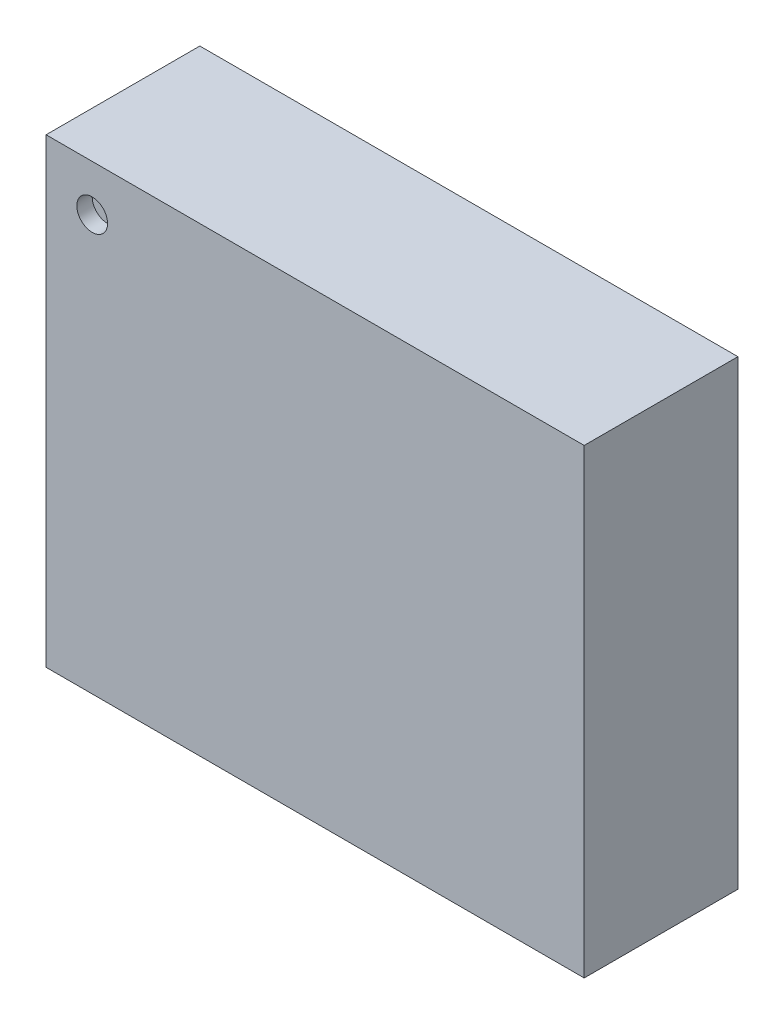
from build123d import *

# Parameters (mm, degrees)
SKETCH1_W           = 3.5
SKETCH1_H           = 3
BOSS_EXTRUDE1_DEPTH = 1
SKETCH2_R           = 0.1
CUT_EXTRUDE1_DEPTH  = 0.1
SKETCH3_W           = 0.23
SKETCH3_H           = 0.35
SKETCH3_W_2         = 0.35
SKETCH3_H_2         = 0.23
BOSS_EXTRUDE2_DEPTH = 0.05


with BuildPart() as part:
    # Sketch1 → Boss-Extrude1 (new body)
    with BuildSketch(Plane.XY):
        with Locations((1.75, 1.5)):
            Rectangle(SKETCH1_W, SKETCH1_H)
    extrude(amount=BOSS_EXTRUDE1_DEPTH)

    # Sketch2 → Cut-Extrude1 (cut)
    with BuildSketch(Plane.XY.offset(1)):
        with Locations((0.3, 2.7)):
            Circle(SKETCH2_R)
    extrude(amount=-CUT_EXTRUDE1_DEPTH, mode=Mode.SUBTRACT)

    # Sketch3 → Boss-Extrude2 (add)
    with BuildSketch(Plane(origin=(0, 0, 0), x_dir=(-1, 0, 0), z_dir=(0, 0, -1))):
        with Locations((-3.255, 2.725)):
            Rectangle(SKETCH3_W, SKETCH3_H)
        with Locations((-2.825, 2.725)):
            Rectangle(SKETCH3_W, SKETCH3_H)
        with Locations((-2.395, 2.725)):
            Rectangle(SKETCH3_W, SKETCH3_H)
        with Locations((-1.965, 2.725)):
            Rectangle(SKETCH3_W, SKETCH3_H)
        with Locations((-1.535, 2.725)):
            Rectangle(SKETCH3_W, SKETCH3_H)
        with Locations((-1.105, 2.725)):
            Rectangle(SKETCH3_W, SKETCH3_H)
        with Locations((-0.675, 2.725)):
            Rectangle(SKETCH3_W, SKETCH3_H)
        Polygon((-0.36, 2.9), (-0.13, 2.9), (-0.13, 2.65), (-0.23, 2.55), (-0.36, 2.55), align=None)
        with Locations((-0.245, 0.275)):
            Rectangle(SKETCH3_W, SKETCH3_H)
        with Locations((-0.675, 0.275)):
            Rectangle(SKETCH3_W, SKETCH3_H)
        with Locations((-1.105, 0.275)):
            Rectangle(SKETCH3_W, SKETCH3_H)
        with Locations((-1.535, 0.275)):
            Rectangle(SKETCH3_W, SKETCH3_H)
        with Locations((-1.965, 0.275)):
            Rectangle(SKETCH3_W, SKETCH3_H)
        with Locations((-2.395, 0.275)):
            Rectangle(SKETCH3_W, SKETCH3_H)
        with Locations((-2.825, 0.275)):
            Rectangle(SKETCH3_W, SKETCH3_H)
        with Locations((-3.255, 0.275)):
            Rectangle(SKETCH3_W, SKETCH3_H)
        with Locations((-3.225, 2.145)):
            Rectangle(SKETCH3_W_2, SKETCH3_H_2)
        with Locations((-3.225, 1.715)):
            Rectangle(SKETCH3_W_2, SKETCH3_H_2)
        with Locations((-3.225, 1.285)):
            Rectangle(SKETCH3_W_2, SKETCH3_H_2)
        with Locations((-3.225, 0.855)):
            Rectangle(SKETCH3_W_2, SKETCH3_H_2)
        with Locations((-0.275, 0.855)):
            Rectangle(SKETCH3_W_2, SKETCH3_H_2)
        with Locations((-0.275, 1.285)):
            Rectangle(SKETCH3_W_2, SKETCH3_H_2)
        with Locations((-0.275, 1.715)):
            Rectangle(SKETCH3_W_2, SKETCH3_H_2)
        with Locations((-0.275, 2.145)):
            Rectangle(SKETCH3_W_2, SKETCH3_H_2)
    extrude(amount=BOSS_EXTRUDE2_DEPTH)


solid = part.part
